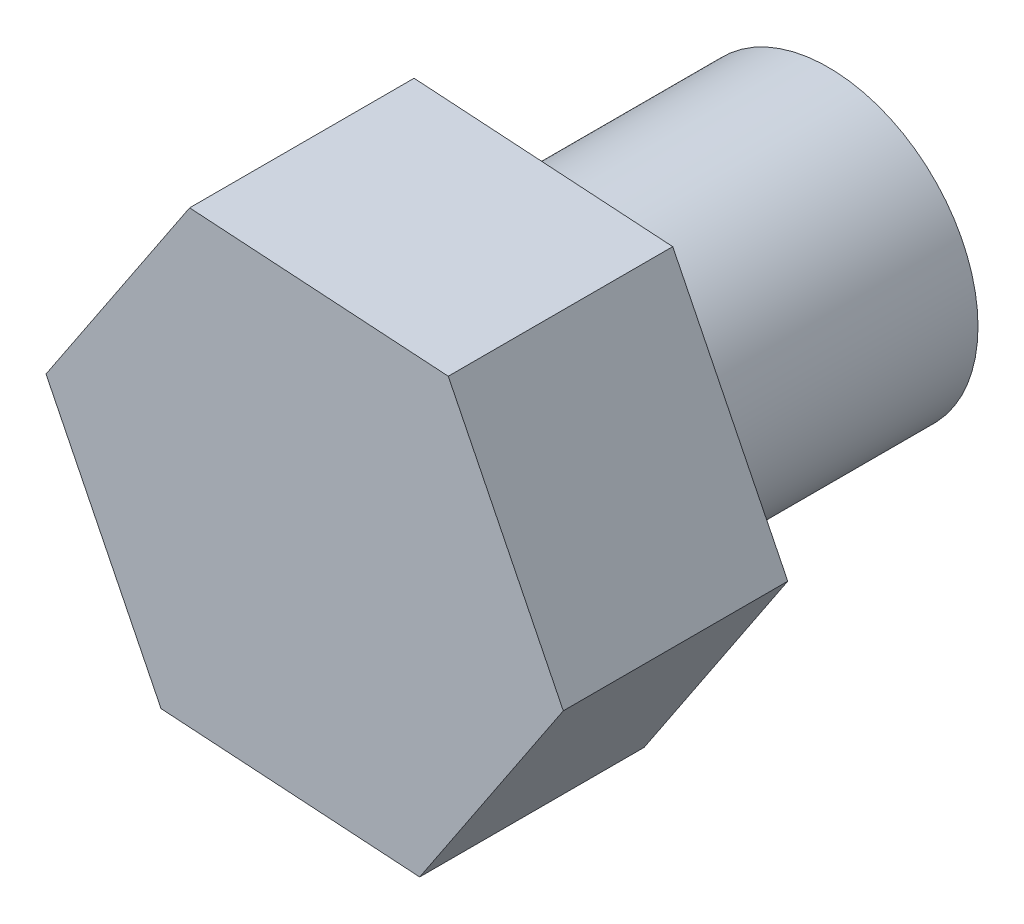
from build123d import *

# Parameters (mm, degrees)
EXTRUDE_1_DEPTH = 3
SKETCH_2_R      = 2
EXTRUDE_2_DEPTH = 4


with BuildPart() as part:
    # 草图1 → 凸台-拉伸1 (new body)
    with BuildSketch(Plane.XY):
        Polygon((1.537378268, -3.104266107), (3.457062442, -0.220724418), (1.919684175, 2.883541688), (-1.537378268, 3.104266107), (-3.457062442, 0.220724418), (-1.919684175, -2.883541688), align=None)
    extrude(amount=EXTRUDE_1_DEPTH)

    # 草图2 → 凸台-拉伸2 (add)
    with BuildSketch(Plane(origin=(0, 0, 0), x_dir=(-1, 0, 0), z_dir=(0, 0, -1))):
        Circle(SKETCH_2_R)
    extrude(amount=EXTRUDE_2_DEPTH)


solid = part.part
